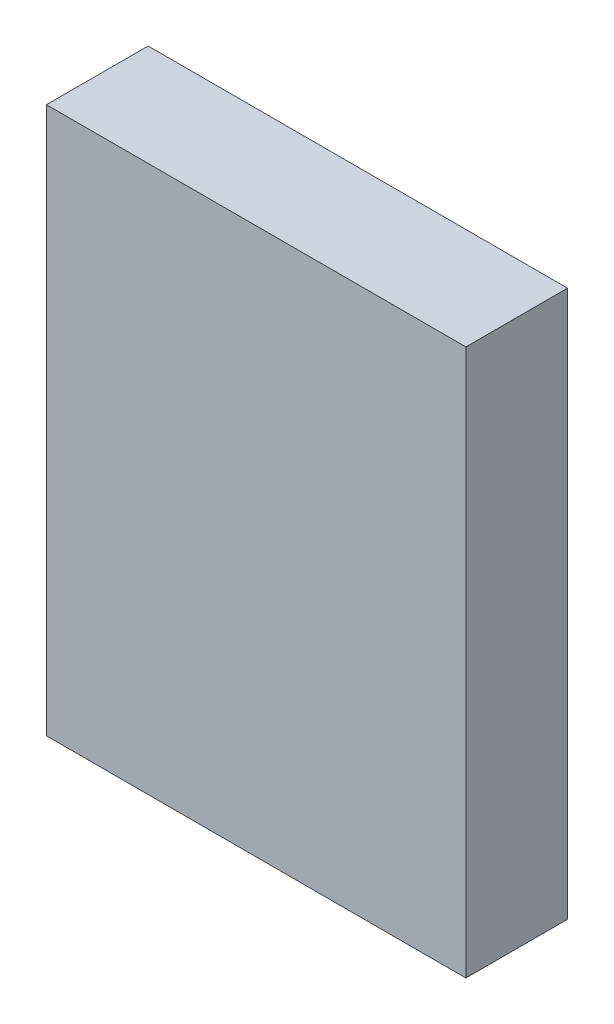
from build123d import *

# Parameters (mm, degrees)
SKETCH1_W           = 52.3875
SKETCH1_H           = 68.2625
BOSS_EXTRUDE1_DEPTH = 12.7


with BuildPart() as part:
    # Sketch1 → Boss-Extrude1 (new body)
    with BuildSketch(Plane.XY):
        with Locations((26.19375, 34.13125)):
            Rectangle(SKETCH1_W, SKETCH1_H)
    extrude(amount=BOSS_EXTRUDE1_DEPTH)


solid = part.part
